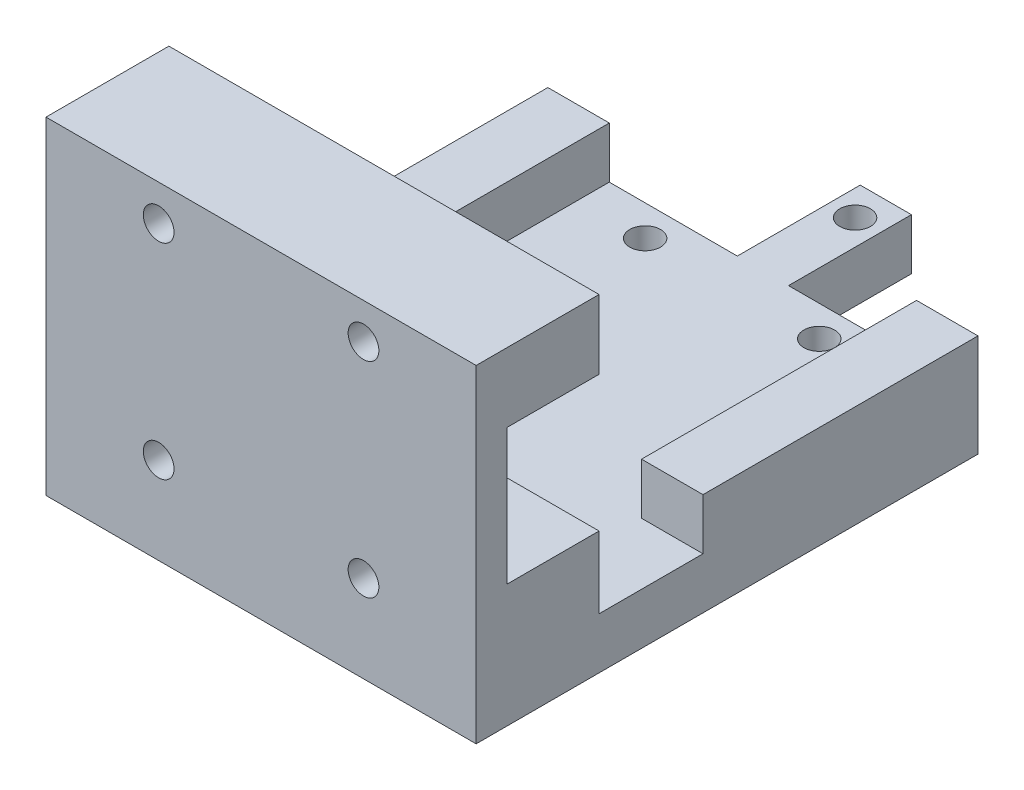
from build123d import *

# Parameters (mm, degrees)
SKETCH1_W             = 42
SKETCH1_H             = 7
SKETCH1_R             = 1.5
BOSS_EXTRUDE1_DEPTH   = 12
SKETCH1_H_2           = 6.75
BOSS_EXTRUDE1_2_DEPTH = 12
SKETCH2_R             = 1.5
BOSS_EXTRUDE2_DEPTH   = 5
SKETCH2_3_W           = 6
SKETCH2_3_H           = 26.85
BOSS_EXTRUDE3_DEPTH   = 5
BOSS_EXTRUDE4_START   = 12
SKETCH1_3_W           = 42
SKETCH1_3_H           = 13.25
BOSS_EXTRUDE4_DEPTH   = 3


with BuildPart() as part:
    # Sketch1 → Boss-Extrude1 (new body)
    with BuildSketch(Plane.XY):
        with Locations((0, -10)):
            Rectangle(SKETCH1_W, SKETCH1_H)
        with Locations((-10, -10)):
            Circle(SKETCH1_R, mode=Mode.SUBTRACT)
        with Locations((10, -10)):
            Circle(SKETCH1_R, mode=Mode.SUBTRACT)
    extrude(amount=BOSS_EXTRUDE1_DEPTH)

    # Sketch2 → Boss-Extrude2 (add)
    with BuildSketch(Plane.XZ.offset(13.5)):
        Polygon((21, 12), (-21, 12), (-21, -37), (-2.5, -37), (-2.5, -49), (2.5, -49), (2.5, -37), (21, -37), align=None)
        with Locations((-8.5, -34)):
            Circle(SKETCH2_R, mode=Mode.SUBTRACT)
        with Locations((8.5, -34)):
            Circle(SKETCH2_R, mode=Mode.SUBTRACT)
        with Locations((0, -46)):
            Circle(SKETCH2_R, mode=Mode.SUBTRACT)
    extrude(amount=BOSS_EXTRUDE2_DEPTH)

    # Sketch2_3 → Boss-Extrude3 (add)
    with BuildSketch(Plane.XZ.offset(13.5)):
        with Locations((18, -23.575)):
            Rectangle(SKETCH2_3_W, SKETCH2_3_H)
        with Locations((-18, -23.575)):
            Rectangle(SKETCH2_3_W, SKETCH2_3_H)
    extrude(amount=-BOSS_EXTRUDE3_DEPTH)



with BuildPart() as body_2:
    # Sketch1 → Boss-Extrude1 2 (new body)
    with BuildSketch(Plane.XY):
        with Locations((0, 10.125)):
            Rectangle(SKETCH1_W, SKETCH1_H_2)
        with Locations((10, 10)):
            Circle(SKETCH1_R, mode=Mode.SUBTRACT)
        with Locations((-10, 10)):
            Circle(SKETCH1_R, mode=Mode.SUBTRACT)
    extrude(amount=BOSS_EXTRUDE1_2_DEPTH)


with BuildPart() as part_1:
    add(part.part)

    add(body_2.part)  # Boss-Extrude4 merges body 2
    # Sketch1_3 → Boss-Extrude4 (add)
    with BuildSketch(Plane.XY.offset(BOSS_EXTRUDE4_START)):
        with Locations((0, 0.125)):
            Rectangle(SKETCH1_3_W, SKETCH1_3_H)
    extrude(amount=-BOSS_EXTRUDE4_DEPTH)


solid = part_1.part
